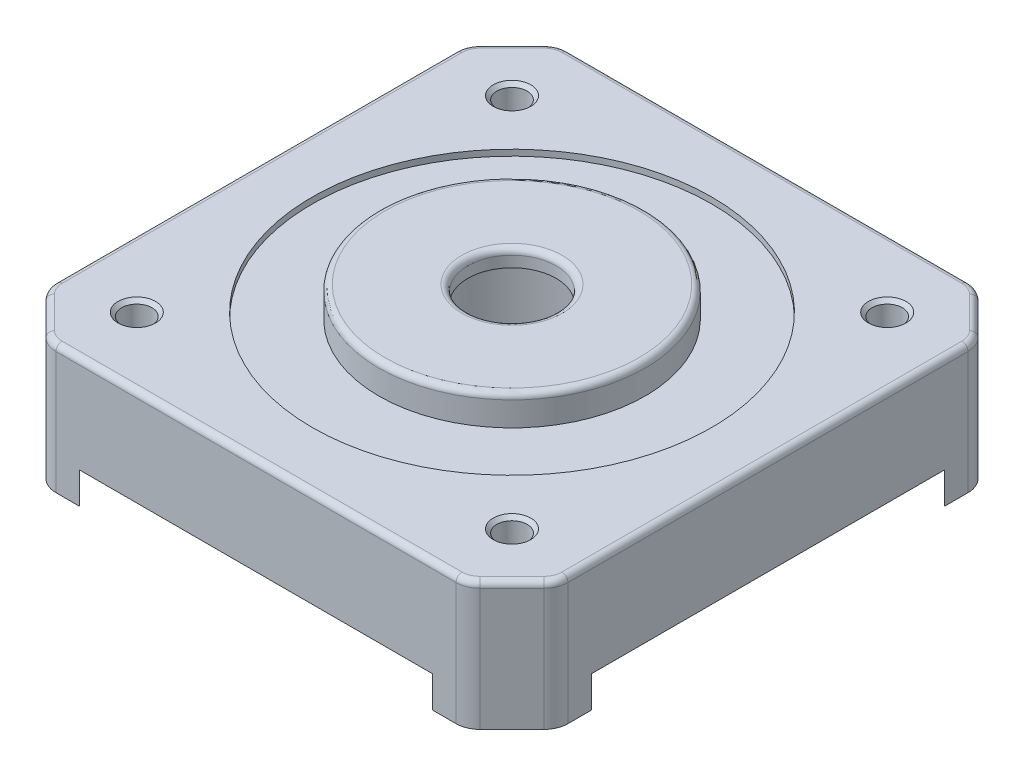
from build123d import *

# Parameters (mm, degrees)
SKETCH_1_R          = 2.65
SKETCH_1_R_2        = 16.5
SKETCH_1_R_3        = 1.25
EXTRUDE_1_DEPTH     = 8
SKETCH_1_3_R        = 16.5
SKETCH_1_3_R_2      = 11
EXTRUDE_2_DEPTH     = 7.5
SKETCH_1_4_R        = 11
SKETCH_1_4_R_2      = 3.65
EXTRUDE_3_DEPTH     = 10
EXTRUDE_4_DEPTH     = 2.6
SKETCH_2_R          = 8
CUT_EXTRUDE_1_DEPTH = 8.6
FILLET_1_R          = 2
FILLET_2_R          = 0.5
CHAMFER_1_SIZE      = 0.3


with BuildPart() as part:
    # Sketch 1 → Extrude 1 (new body)
    with BuildSketch(Plane(origin=(0, 0, 0), x_dir=(1, 0, 0), z_dir=(0, 1, 0))):
        with BuildLine():
            ThreePointArc((-14.600256847, 21.15), (-18.172644276, 18.172644276), (-21.15, 14.600256847))
            Line((-21.15, 14.600256847), (-21.15, -14.600256847))
            ThreePointArc((-21.15, -14.600256847), (-18.172644276, -18.172644276), (-14.600256847, -21.15))
            Line((-14.600256847, -21.15), (14.600256847, -21.15))
            ThreePointArc((14.600256847, -21.15), (18.172644276, -18.172644276), (21.15, -14.600256847))
            Line((21.15, -14.600256847), (21.15, 14.600256847))
            ThreePointArc((21.15, 14.600256847), (18.172644276, 18.172644276), (14.600256847, 21.15))
            Line((14.600256847, 21.15), (-14.600256847, 21.15))
        make_face()
        with Locations((-15.5, -15.5)):
            Circle(SKETCH_1_R, mode=Mode.SUBTRACT)
        with Locations((15.5, -15.5)):
            Circle(SKETCH_1_R, mode=Mode.SUBTRACT)
        Circle(SKETCH_1_R_2, mode=Mode.SUBTRACT)
        with Locations((-15.5, 15.5)):
            Circle(SKETCH_1_R, mode=Mode.SUBTRACT)
        with Locations((15.5, 15.5)):
            Circle(SKETCH_1_R, mode=Mode.SUBTRACT)
        with Locations((15.5, -15.5)):
            Circle(SKETCH_1_R)
        with Locations((15.5, -15.5)):
            Circle(SKETCH_1_R_3, mode=Mode.SUBTRACT)
        with Locations((-15.5, -15.5)):
            Circle(SKETCH_1_R)
        with Locations((-15.5, -15.5)):
            Circle(SKETCH_1_R_3, mode=Mode.SUBTRACT)
        with Locations((-15.5, 15.5)):
            Circle(SKETCH_1_R)
        with Locations((-15.5, 15.5)):
            Circle(SKETCH_1_R_3, mode=Mode.SUBTRACT)
        with Locations((15.5, 15.5)):
            Circle(SKETCH_1_R)
        with Locations((15.5, 15.5)):
            Circle(SKETCH_1_R_3, mode=Mode.SUBTRACT)
        with BuildLine():
            ThreePointArc((-14.600256847, -21.15), (-18.172644276, -18.172644276), (-21.15, -14.600256847))
            Line((-21.15, -14.600256847), (-21.15, -17.35))
            Line((-21.15, -17.35), (-17.35, -21.15))
            Line((-17.35, -21.15), (-14.600256847, -21.15))
        make_face()
        with BuildLine():
            Line((-17.35, 21.15), (-21.15, 17.35))
            Line((-21.15, 17.35), (-21.15, 14.600256847))
            ThreePointArc((-21.15, 14.600256847), (-18.172644276, 18.172644276), (-14.600256847, 21.15))
            Line((-14.600256847, 21.15), (-17.35, 21.15))
        make_face()
        with BuildLine():
            Line((17.35, 21.15), (14.600256847, 21.15))
            ThreePointArc((14.600256847, 21.15), (18.172644276, 18.172644276), (21.15, 14.600256847))
            Line((21.15, 14.600256847), (21.15, 17.35))
            Line((21.15, 17.35), (17.35, 21.15))
        make_face()
        with BuildLine():
            ThreePointArc((21.15, -14.600256847), (18.172644276, -18.172644276), (14.600256847, -21.15))
            Line((14.600256847, -21.15), (17.35, -21.15))
            Line((17.35, -21.15), (21.15, -17.35))
            Line((21.15, -17.35), (21.15, -14.600256847))
        make_face()
    extrude(amount=EXTRUDE_1_DEPTH)

    # Sketch 1_3 → Extrude 2 (add)
    with BuildSketch(Plane(origin=(0, 0, 0), x_dir=(1, 0, 0), z_dir=(0, 1, 0))):
        Circle(SKETCH_1_3_R)
        Circle(SKETCH_1_3_R_2, mode=Mode.SUBTRACT)
    extrude(amount=EXTRUDE_2_DEPTH)

    # Sketch 1_4 → Extrude 3 (add)
    with BuildSketch(Plane(origin=(0, 0, 0), x_dir=(1, 0, 0), z_dir=(0, 1, 0))):
        Circle(SKETCH_1_4_R)
        Circle(SKETCH_1_4_R_2, mode=Mode.SUBTRACT)
    extrude(amount=EXTRUDE_3_DEPTH)

    # Sketch 1_5 → Extrude 4 (add)
    with BuildSketch(Plane(origin=(0, 0, 0), x_dir=(1, 0, 0), z_dir=(0, 1, 0))):
        with BuildLine():
            ThreePointArc((-14.600256847, -21.15), (-18.172644276, -18.172644276), (-21.15, -14.600256847))
            Line((-21.15, -14.600256847), (-21.15, -17.35))
            Line((-21.15, -17.35), (-17.35, -21.15))
            Line((-17.35, -21.15), (-14.600256847, -21.15))
        make_face()
        with BuildLine():
            ThreePointArc((21.15, -14.600256847), (18.172644276, -18.172644276), (14.600256847, -21.15))
            Line((14.600256847, -21.15), (17.35, -21.15))
            Line((17.35, -21.15), (21.15, -17.35))
            Line((21.15, -17.35), (21.15, -14.600256847))
        make_face()
        with BuildLine():
            Line((-17.35, 21.15), (-21.15, 17.35))
            Line((-21.15, 17.35), (-21.15, 14.600256847))
            ThreePointArc((-21.15, 14.600256847), (-18.172644276, 18.172644276), (-14.600256847, 21.15))
            Line((-14.600256847, 21.15), (-17.35, 21.15))
        make_face()
        with BuildLine():
            Line((17.35, 21.15), (14.600256847, 21.15))
            ThreePointArc((14.600256847, 21.15), (18.172644276, 18.172644276), (21.15, 14.600256847))
            Line((21.15, 14.600256847), (21.15, 17.35))
            Line((21.15, 17.35), (17.35, 21.15))
        make_face()
    extrude(amount=-EXTRUDE_4_DEPTH)

    # Sketch 2 → Cut-Extrude 1 (cut)
    with BuildSketch(Plane.XZ):
        Circle(SKETCH_2_R)
    extrude(amount=-CUT_EXTRUDE_1_DEPTH, mode=Mode.SUBTRACT)

    # Fillet 1
    fillet_1_edges = [part.edges().sort_by_distance(p)[0] for p in [
        (-17.35, 2.7, 21.15),
        (-21.15, 2.7, 17.35),
        (-21.15, 2.7, -17.35),
        (-17.35, 2.7, -21.15),
        (17.35, 2.7, -21.15),
        (21.15, 2.7, -17.35),
        (21.15, 2.7, 17.35),
        (17.35, 2.7, 21.15),
    ]]
    fillet(fillet_1_edges, radius=FILLET_1_R)

    # Fillet 2
    fillet_2_edges = [part.edges().sort_by_distance(p)[0] for p in [
        (21.15, 8, 0),
        (19.25, 8, 19.25),
        (0, 8, 21.15),
        (19.25, 8, -19.25),
        (0, 8, -21.15),
        (-19.25, 8, -19.25),
        (-21.15, 8, 0),
        (-19.25, 8, 19.25),
        (20.997759065, 8, -17.28693974),
        (17.28693974, 8, -20.997759065),
        (-17.28693974, 8, -20.997759065),
        (-20.997759065, 8, -17.28693974),
        (-20.997759065, 8, 17.28693974),
        (-17.28693974, 8, 20.997759065),
        (17.28693974, 8, 20.997759065),
        (20.997759065, 8, 17.28693974),
        (-3.65, 10, 0),
        (-11, 10, 0),
    ]]
    fillet(fillet_2_edges, radius=FILLET_2_R)

    # Chamfer 1
    chamfer_1_edges = [part.edges().sort_by_distance(p)[0] for p in [
        (-16.75, 8, -15.5),
        (14.25, 8, -15.5),
        (14.25, 8, 15.5),
        (-16.75, 8, 15.5),
    ]]
    chamfer(chamfer_1_edges, length=CHAMFER_1_SIZE)


solid = part.part
